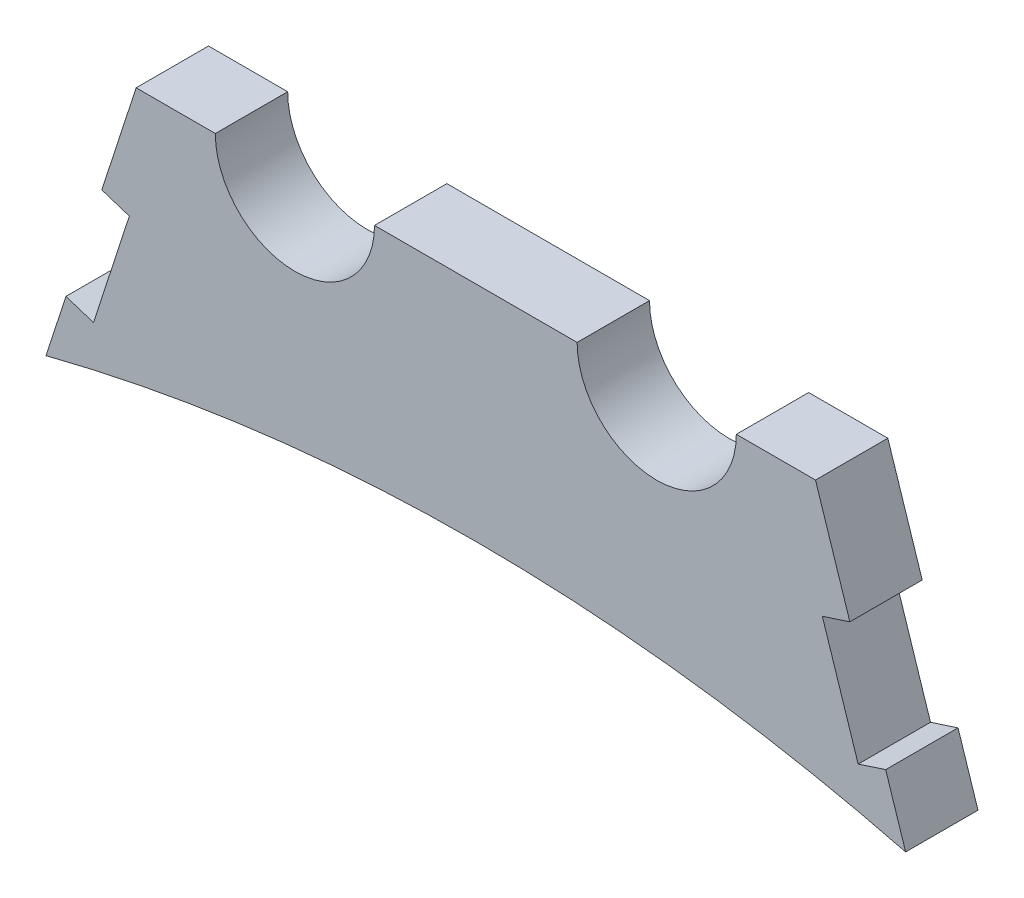
from build123d import *

# Parameters (mm, degrees)
BOSS_EXTRUDE2_DEPTH = 6.35


with BuildPart() as part:
    # Sketch1 → Boss-Extrude2 (new body)
    with BuildSketch(Plane.XY):
        with BuildLine():
            Line((37.717239544, 147.658964649), (35.965487423, 153.043027332))
            Line((35.965487423, 153.043027332), (33.550115758, 152.257164929))
            Line((33.550115758, 152.257164929), (30.406666146, 161.918651592))
            Line((30.406666146, 161.918651592), (32.822037812, 162.704513995))
            Line((32.822037812, 162.704513995), (29.806543337, 171.972726708))
            Line((29.806543337, 171.972726708), (22.86, 171.972726708))
            ThreePointArc((22.86, 171.972726708), (15.875, 164.987726708), (8.89, 171.972726708))
            Line((8.89, 171.972726708), (-8.89, 171.972726708))
            ThreePointArc((-8.89, 171.972726708), (-15.875, 164.987726708), (-22.86, 171.972726708))
            Line((-22.86, 171.972726708), (-29.806543337, 171.972726708))
            Line((-29.806543337, 171.972726708), (-32.822037812, 162.704513995))
            Line((-32.822037812, 162.704513995), (-30.406666146, 161.918651592))
            Line((-30.406666146, 161.918651592), (-33.550115758, 152.257164929))
            Line((-33.550115758, 152.257164929), (-35.965487423, 153.043027332))
            Line((-35.965487423, 153.043027332), (-37.717239544, 147.658964649))
            ThreePointArc((-37.717239544, 147.658964649), (0, 152.4), (37.717239544, 147.658964649))
        make_face()
    extrude(amount=BOSS_EXTRUDE2_DEPTH)


solid = part.part
